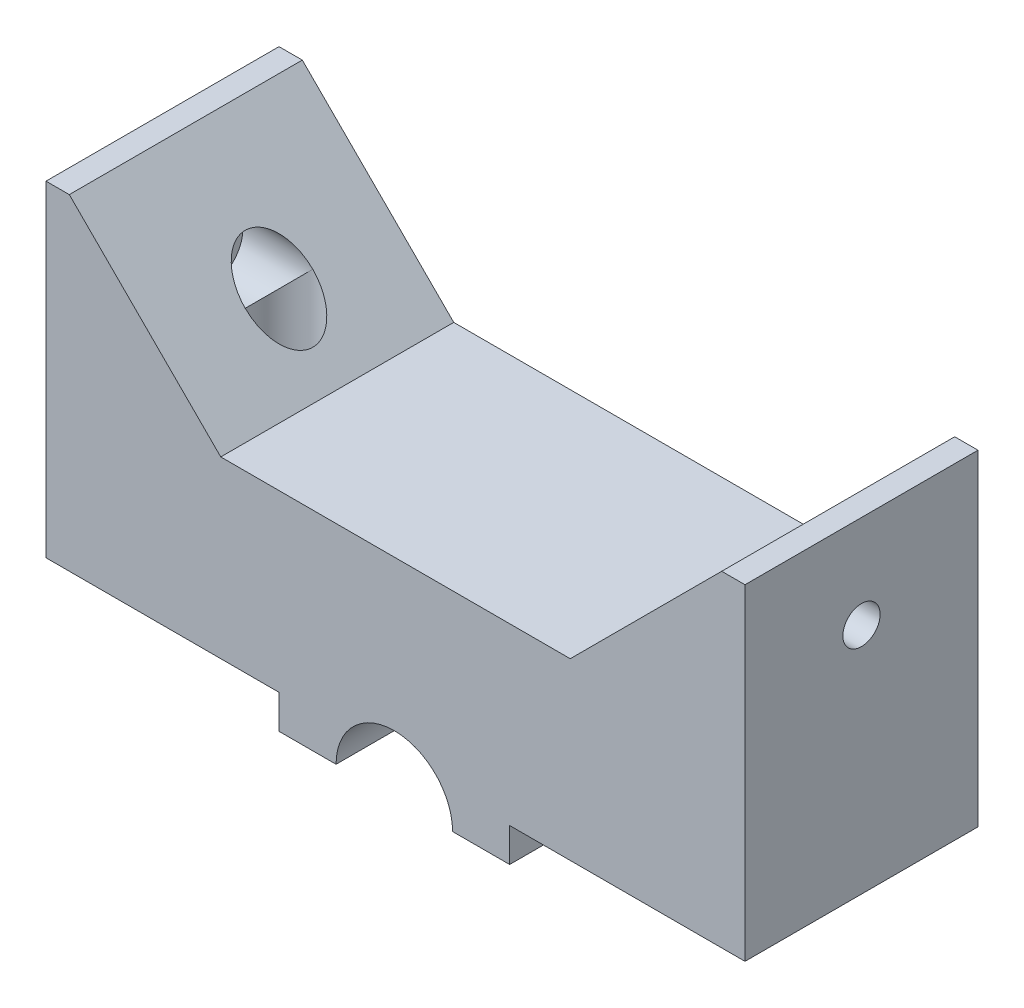
from build123d import *

# Parameters (mm, degrees)
BOSS_EXTRU_1_DEPTH           = 5
BOSS_EXTRU_2_DEPTH           = 15
ESQUISSE3_R                  = 1.6
ENL_V_MAT_EXTRU_1_DEPTH      = 70.166465863
ENL_V_MAT_EXTRU_2_DEPTH      = 26
ENL_V_MAT_EXTRU_2_DEPTH_BACK = 26
ESQUISSE4_R                  = 2.9
ESQUISSE4_R_2                = 1.6
ESQUISSE5_R                  = 1.6
ENL_V_MAT_EXTRU_3_DEPTH      = 25
ENL_V_MAT_EXTRU_4_DEPTH      = 25
ENL_V_MAT_EXTRU_4_DEPTH_BACK = 10
ESQUISSE6_R                  = 2.9
ESQUISSE6_R_2                = 1.6


with BuildPart() as part:
    # Esquisse1 → Boss.-Extru.1 (new body)
    with BuildSketch(Plane.XY):
        Polygon((15, 15), (2, 28), (0, 28), (0, 0), (20, 0), (20, -2.9), (39.8, -2.9), (39.8, 0), (60, 0), (60, 28), (58, 28), (45, 15), align=None)
    extrude(amount=BOSS_EXTRU_1_DEPTH)

    # Esquisse2 → Boss.-Extru.2 (add)
    with BuildSketch(Plane.XY.offset(5)):
        with BuildLine():
            Line((2, 28), (0, 28))
            Line((0, 28), (0, 0))
            Line((0, 0), (20, 0))
            Line((20, 0), (20, -2.9))
            Line((20, -2.9), (24.9, -2.9))
            ThreePointArc((24.9, -2.9), (29.9, 2.1), (34.9, -2.9))
            Line((34.9, -2.9), (39.8, -2.9))
            Line((39.8, -2.9), (39.8, 0))
            Line((39.8, 0), (60, 0))
            Line((60, 0), (60, 28))
            Line((60, 28), (58, 28))
            Line((58, 28), (45, 15))
            Line((45, 15), (15, 15))
            Line((15, 15), (2, 28))
        make_face()
    extrude(amount=BOSS_EXTRU_2_DEPTH)

    # Esquisse3 → Enlèv. mat.-Extru.1 (cut, through all)
    with BuildSketch(Plane(origin=(60, 0, 0), x_dir=(0, 0, -1), z_dir=(1, 0, 0))):
        with Locations((-10, 20)):
            Circle(ESQUISSE3_R)
    extrude(amount=-ENL_V_MAT_EXTRU_1_DEPTH, mode=Mode.SUBTRACT)

    # Esquisse4 → Enlèv. mat.-Extru.2 (cut, two sides: drawn at the far end of the back side and taken through both)
    with BuildSketch(Plane.ZY.offset(-30).offset(-ENL_V_MAT_EXTRU_2_DEPTH_BACK)):
        with Locations((10, 20)):
            Circle(ESQUISSE4_R)
        with Locations((10, 20)):
            Circle(ESQUISSE4_R_2, mode=Mode.SUBTRACT)
    extrude(amount=ENL_V_MAT_EXTRU_2_DEPTH + ENL_V_MAT_EXTRU_2_DEPTH_BACK, mode=Mode.SUBTRACT)

    # Esquisse5 → Enlèv. mat.-Extru.3 (cut)
    with BuildSketch(Plane.XZ):
        with Locations((49.9, 10)):
            Circle(ESQUISSE5_R)
        with Locations((10, 10)):
            Circle(ESQUISSE5_R)
    extrude(amount=-ENL_V_MAT_EXTRU_3_DEPTH, mode=Mode.SUBTRACT)

    # Esquisse6 → Enlèv. mat.-Extru.4 (cut, two sides: drawn at the far end of the back side and taken through both)
    # profile 1 of 2: a face of its own
    with BuildSketch(Plane(origin=(0, 15, 0), x_dir=(1, 0, 0), z_dir=(0, 1, 0)).offset(-ENL_V_MAT_EXTRU_4_DEPTH_BACK)):
        with Locations((10, -10)):
            Circle(ESQUISSE6_R)
        with Locations((10, -10)):
            Circle(ESQUISSE6_R_2, mode=Mode.SUBTRACT)
    # profile 2 of 2: a face of its own
    with BuildSketch(Plane(origin=(0, 15, 0), x_dir=(1, 0, 0), z_dir=(0, 1, 0)).offset(-ENL_V_MAT_EXTRU_4_DEPTH_BACK)):
        with Locations((49.9, -10)):
            Circle(ESQUISSE6_R)
        with Locations((49.9, -10)):
            Circle(ESQUISSE6_R_2, mode=Mode.SUBTRACT)
    extrude(amount=ENL_V_MAT_EXTRU_4_DEPTH + ENL_V_MAT_EXTRU_4_DEPTH_BACK, mode=Mode.SUBTRACT)


solid = part.part
